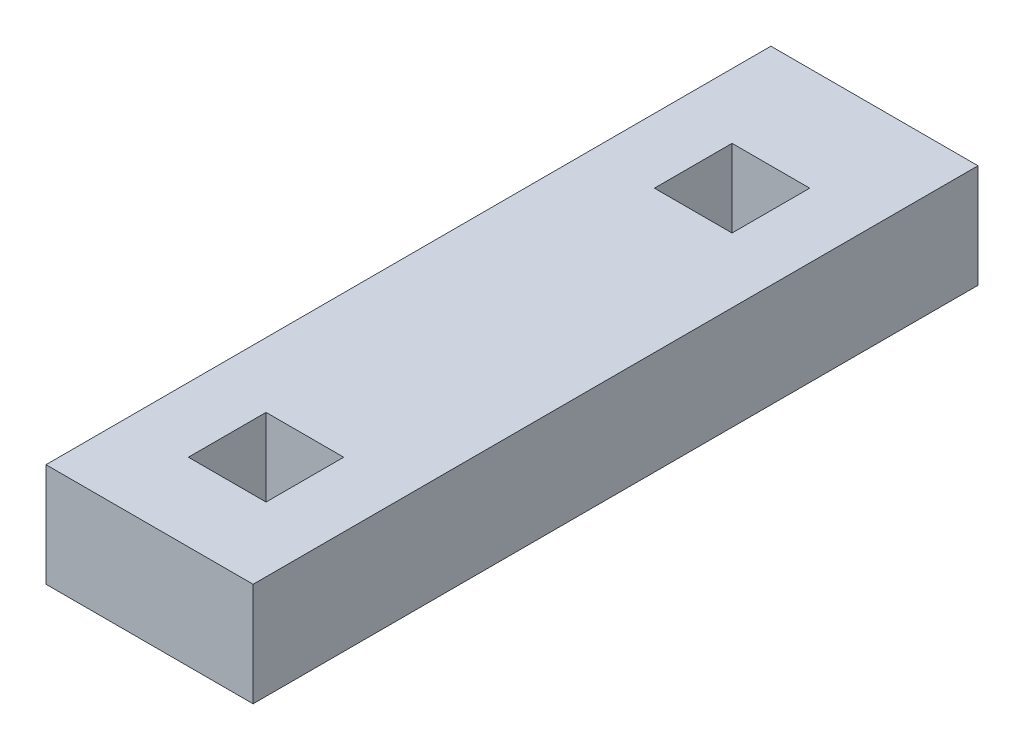
from build123d import *

# Parameters (mm, degrees)
SKETCH1_W           = 203.2
SKETCH1_H           = 101.6
BOSS_EXTRUDE1_DEPTH = 711.2
SKETCH2_W           = 76.2
SKETCH2_H           = 76.2
CUT_EXTRUDE1_DEPTH  = 76.2


with BuildPart() as part:
    # Sketch1 → Boss-Extrude1 (new body)
    with BuildSketch(Plane.XY):
        with Locations((101.6, 50.8)):
            Rectangle(SKETCH1_W, SKETCH1_H)
    extrude(amount=BOSS_EXTRUDE1_DEPTH)

    # Sketch2 → Cut-Extrude1 (cut)
    with BuildSketch(Plane(origin=(0, 101.6, 0), x_dir=(1, 0, 0), z_dir=(0, 1, 0))):
        with Locations((101.6, -139.7)):
            Rectangle(SKETCH2_W, SKETCH2_H)
        with Locations((101.6, -596.9)):
            Rectangle(SKETCH2_W, SKETCH2_H)
    extrude(amount=-CUT_EXTRUDE1_DEPTH, mode=Mode.SUBTRACT)


solid = part.part
